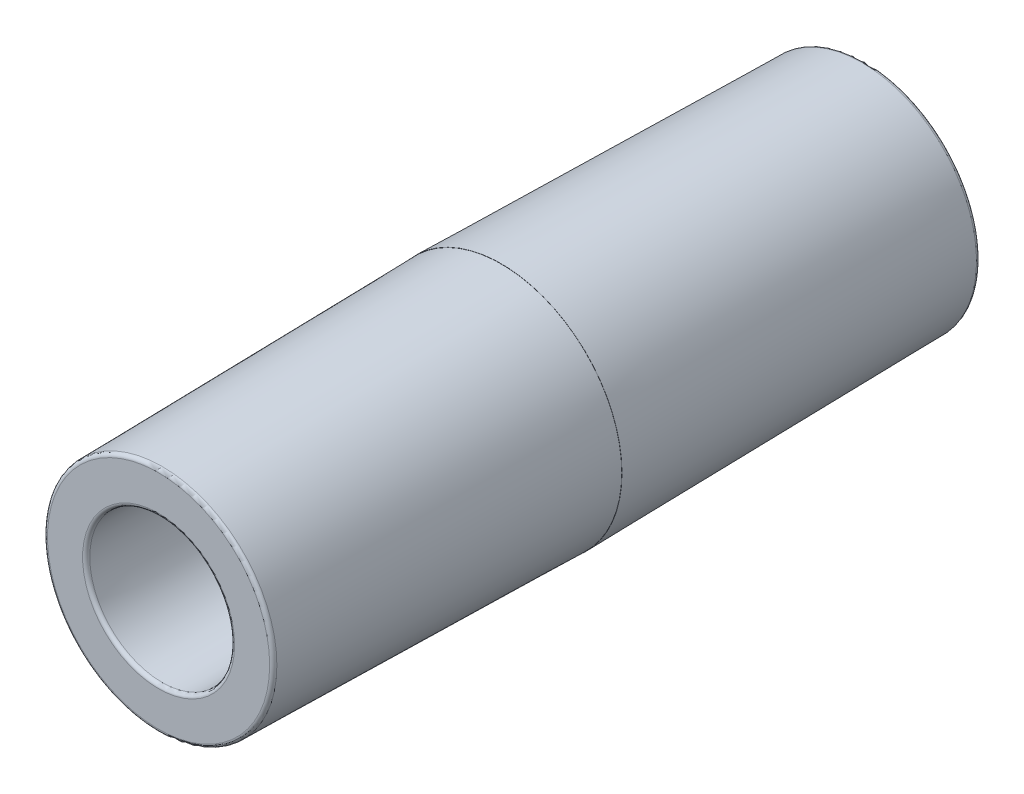
from build123d import *

# Parameters (mm, degrees)
FILLET1_R = 0.254


with BuildPart() as part:
    # Sketch1 → Revolve1 (revolve)
    with BuildSketch(Plane.XZ):
        Polygon((5.047062695, 23.876), (4.8387, 0), (4.8514, 0), (5.073062442, -25.4), (7.976741351, -25.4), (8.4201, 0), (8.4074, 0), (7.99064287, 23.876), align=None)
    revolve(axis=Axis((0, 0, 23.867968573), (0, 0, -1)))

    # Fillet1
    fillet1_edges = [part.edges().sort_by_distance(p)[0] for p in [
        (-7.99064287, 0, 23.876),
        (-7.976741351, 0, -25.4),
        (-5.073062442, 0, -25.4),
        (-5.047062695, 0, 23.876),
    ]]
    fillet(fillet1_edges, radius=FILLET1_R)


solid = part.part
